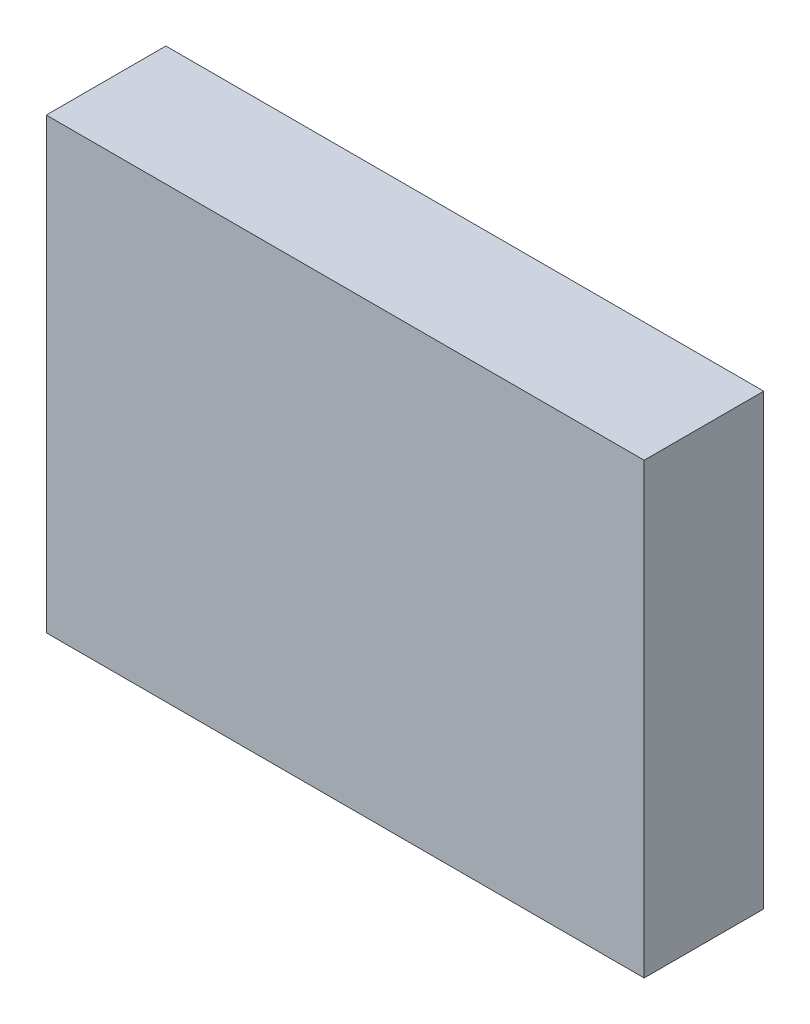
from build123d import *

# Parameters (mm, degrees)
SKETCH1_W           = 100
SKETCH1_H           = 75
BOSS_EXTRUDE1_DEPTH = 10


with BuildPart() as part:
    # Sketch1 → Boss-Extrude1 (new body, symmetric)
    with BuildSketch(Plane.XY):
        Rectangle(SKETCH1_W, SKETCH1_H)
    extrude(amount=BOSS_EXTRUDE1_DEPTH, both=True)


solid = part.part
